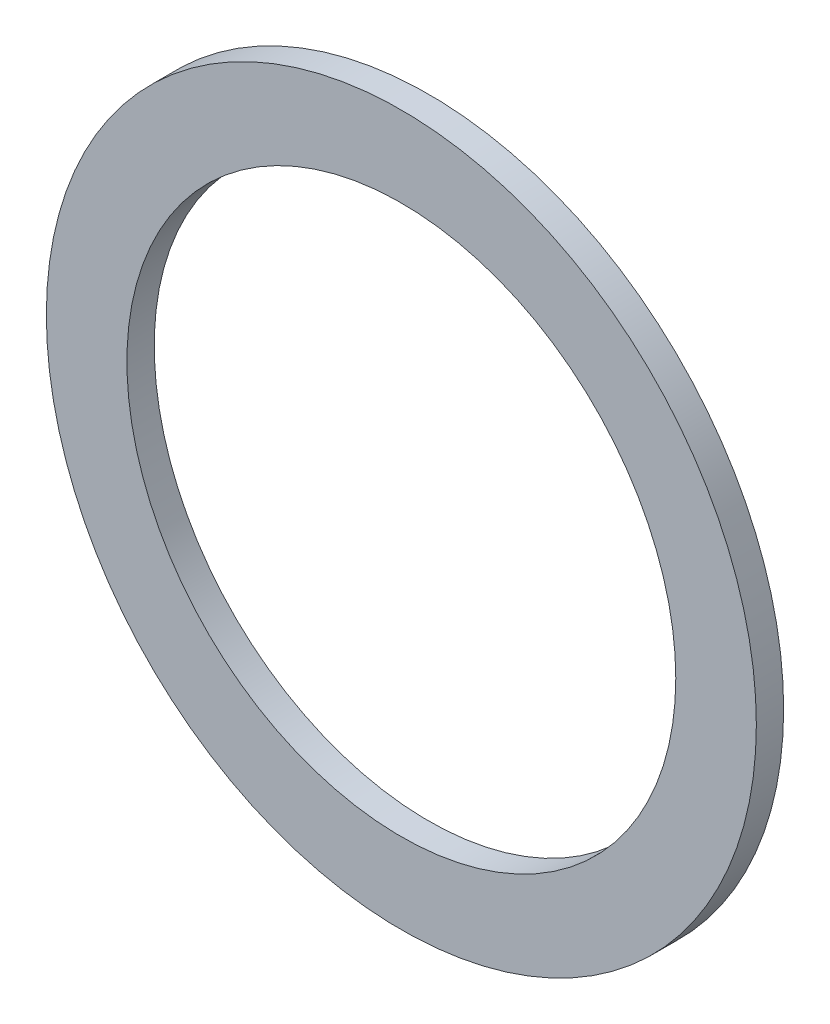
from build123d import *

# Parameters (mm, degrees)
SKETCH_1_R      = 6.5
SKETCH_1_R_2    = 5.025
EXTRUDE_1_DEPTH = 0.5


with BuildPart() as part:
    # ｽｹｯﾁ1 → ﾎﾞｽ - 押し出し1 (new body)
    with BuildSketch(Plane(origin=(0, 0, 0), x_dir=(0, 1, 0), z_dir=(0, 0, 1))):
        Circle(SKETCH_1_R)
        Circle(SKETCH_1_R_2, mode=Mode.SUBTRACT)
    extrude(amount=EXTRUDE_1_DEPTH)


solid = part.part
